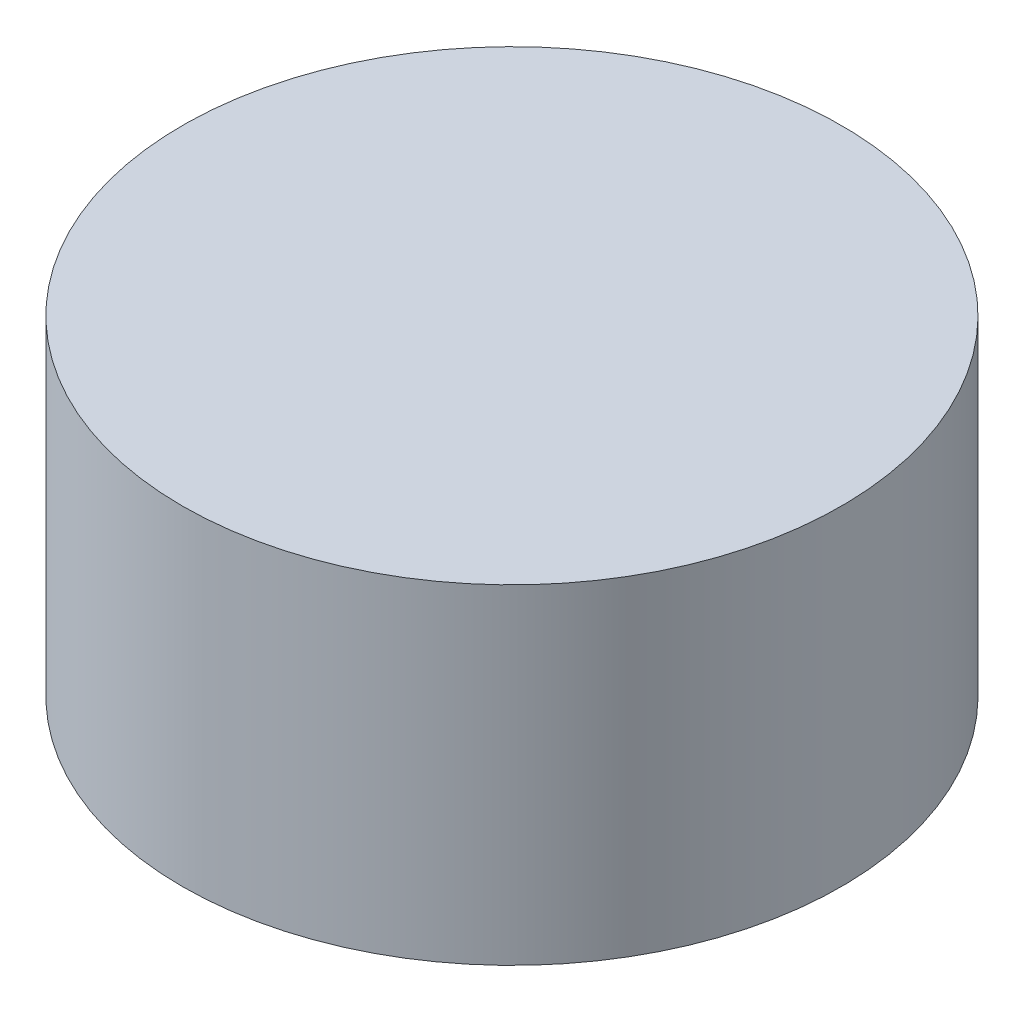
from build123d import *

# Parameters (mm, degrees)
SKETCH2_R           = 20
BOSS_EXTRUDE1_DEPTH = 20


with BuildPart() as part:
    # Sketch2 → Boss-Extrude1 (new body)
    with BuildSketch(Plane(origin=(0, 0, 0), x_dir=(1, 0, 0), z_dir=(0, 1, 0))):
        Circle(SKETCH2_R)
    extrude(amount=BOSS_EXTRUDE1_DEPTH)


solid = part.part
